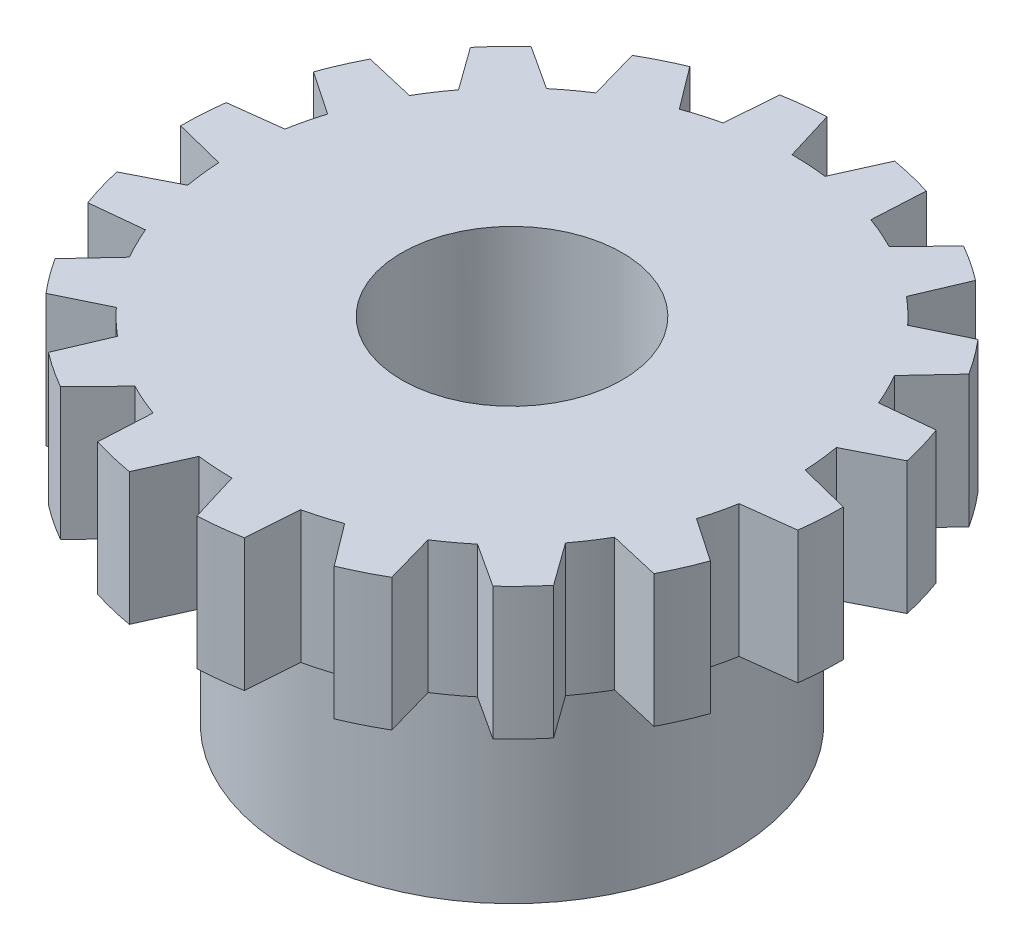
from build123d import *

# Parameters (mm, degrees)
SKETCH1_R           = 7.5
BOSS_EXTRUDE1_DEPTH = 3
SKETCH2_R           = 5
BOSS_EXTRUDE2_DEPTH = 5
CUT_EXTRUDE1_REACH  = 10
SKETCH3_R           = 2.5
CUT_EXTRUDE2_REACH  = 10


with BuildPart() as part:
    # Sketch1 → Boss-Extrude1 (new body)
    with BuildSketch(Plane(origin=(0, 0, 0), x_dir=(1, 0, 0), z_dir=(0, 1, 0))):
        Circle(SKETCH1_R)
    extrude(amount=BOSS_EXTRUDE1_DEPTH)

    # Sketch2 → Boss-Extrude2 (add)
    with BuildSketch(Plane(origin=(0, 0, 0), x_dir=(-1, 0, 0), z_dir=(0, -1, 0))):
        Circle(SKETCH2_R)
    extrude(amount=BOSS_EXTRUDE2_DEPTH)

    # Sketch3 → Cut-Extrude1 (cut, up to next)
    with BuildSketch(Plane(origin=(0, 3, 0), x_dir=(1, 0, 0), z_dir=(0, 1, 0)), mode=Mode.PRIVATE) as cut_extrude1_sk1:
        Circle(SKETCH3_R)
    cut_extrude1_tool1 = extrude(cut_extrude1_sk1.sketch, amount=-CUT_EXTRUDE1_REACH, mode=Mode.PRIVATE) & part.part
    add(cut_extrude1_tool1.solids().sort_by_distance((0, 3, 0))[0], mode=Mode.SUBTRACT)

    # Sketch4 → Cut-Extrude2 (cut, up to next)
    with BuildSketch(Plane(origin=(0, 3, 0), x_dir=(1, 0, 0), z_dir=(0, 1, 0)), mode=Mode.PRIVATE) as cut_extrude2_sk1:
        with BuildLine():
            Line((-1.289148398, -7.388375762), (-0.799951005, -6.299410956))
            ThreePointArc((-0.799951005, -6.299410956), (-0.400774519, -6.337340119), (0, -6.35))
            Line((0, -6.35), (0.348116052, -7.491916658))
            ThreePointArc((0.348116052, -7.491916658), (-0.473355731, -7.485047385), (-1.289148398, -7.388375762))
        make_face()
    cut_extrude2_tool1 = extrude(cut_extrude2_sk1.sketch, amount=-CUT_EXTRUDE2_REACH, mode=Mode.PRIVATE) & part.part
    add(cut_extrude2_tool1.solids().sort_by_distance((-0.440605, 3, 6.967167))[0], mode=Mode.SUBTRACT)
    # Sketch4 → Cut-Extrude2 (cut, up to next)
    with BuildSketch(Plane(origin=(0, 3, 0), x_dir=(1, 0, 0), z_dir=(0, 1, 0)), mode=Mode.PRIVATE) as cut_extrude2_sk2:
        with BuildLine():
            Line((-2.235264324, -7.159161501), (-2.17182791, -5.967048142))
            ThreePointArc((-2.17182791, -5.967048142), (-2.544102834, -5.818078787), (-2.906233494, -5.645910633))
            Line((-2.906233494, -5.645910633), (-3.738376574, -6.501887464))
            ThreePointArc((-3.738376574, -6.501887464), (-3.004845867, -6.871746599), (-2.235264324, -7.159161501))
        make_face()
    cut_extrude2_tool2 = extrude(cut_extrude2_sk2.sketch, amount=-CUT_EXTRUDE2_REACH, mode=Mode.PRIVATE) & part.part
    add(cut_extrude2_tool2.solids().sort_by_distance((-2.796945, 3, 6.3963))[0], mode=Mode.SUBTRACT)
    # Sketch4 → Cut-Extrude2 (cut, up to next)
    with BuildSketch(Plane(origin=(0, 3, 0), x_dir=(1, 0, 0), z_dir=(0, 1, 0)), mode=Mode.PRIVATE) as cut_extrude2_sk3:
        with BuildLine():
            Line((-4.549038834, -5.962905809), (-4.081701322, -4.864382214))
            ThreePointArc((-4.081701322, -4.864382214), (-4.3805748, -4.597071287), (-4.661981333, -4.311430164))
            Line((-4.661981333, -4.311430164), (-5.736701363, -4.831175579))
            ThreePointArc((-5.736701363, -4.831175579), (-5.173907244, -5.429611756), (-4.549038834, -5.962905809))
        make_face()
    cut_extrude2_tool3 = extrude(cut_extrude2_sk3.sketch, amount=-CUT_EXTRUDE2_REACH, mode=Mode.PRIVATE) & part.part
    add(cut_extrude2_tool3.solids().sort_by_distance((-4.815932, 3, 5.053944))[0], mode=Mode.SUBTRACT)
    # Sketch4 → Cut-Extrude2 (cut, up to next)
    with BuildSketch(Plane(origin=(0, 3, 0), x_dir=(1, 0, 0), z_dir=(0, 1, 0)), mode=Mode.PRIVATE) as cut_extrude2_sk4:
        with BuildLine():
            Line((-6.314132123, -4.047435674), (-5.499261314, -3.175))
            ThreePointArc((-5.499261314, -3.175), (-5.688684795, -2.821589145), (-5.855425419, -2.456927586))
            Line((-5.855425419, -2.456927586), (-7.043095302, -2.577752619))
            ThreePointArc((-7.043095302, -2.577752619), (-6.718919049, -3.332585604), (-6.314132123, -4.047435674))
        make_face()
    cut_extrude2_tool4 = extrude(cut_extrude2_sk4.sketch, amount=-CUT_EXTRUDE2_REACH, mode=Mode.PRIVATE) & part.part
    add(cut_extrude2_tool4.solids().sort_by_distance((-6.254046, 3, 3.102009))[0], mode=Mode.SUBTRACT)
    # Sketch4 → Cut-Extrude2 (cut, up to next)
    with BuildSketch(Plane(origin=(0, 3, 0), x_dir=(1, 0, 0), z_dir=(0, 1, 0)), mode=Mode.PRIVATE) as cut_extrude2_sk5:
        with BuildLine():
            Line((-7.317647892, -1.643785062), (-6.253529232, -1.102665928))
            ThreePointArc((-6.253529232, -1.102665928), (-6.310655448, -0.705781709), (-6.342618783, -0.306083282))
            Line((-6.342618783, -0.306083282), (-7.499988003, -0.01341465))
            ThreePointArc((-7.499988003, -0.01341465), (-7.453530056, -0.833600444), (-7.317647892, -1.643785062))
        make_face()
    cut_extrude2_tool5 = extrude(cut_extrude2_sk5.sketch, amount=-CUT_EXTRUDE2_REACH, mode=Mode.PRIVATE) & part.part
    add(cut_extrude2_tool5.solids().sort_by_distance((-6.93783, 3, 0.775925))[0], mode=Mode.SUBTRACT)
    # Sketch4 → Cut-Extrude2 (cut, up to next)
    with BuildSketch(Plane(origin=(0, 3, 0), x_dir=(1, 0, 0), z_dir=(0, 1, 0)), mode=Mode.PRIVATE) as cut_extrude2_sk6:
        with BuildLine():
            Line((-7.438547328, 0.958130288), (-6.253529232, 1.102665928))
            ThreePointArc((-6.253529232, 1.102665928), (-6.171467918, 1.495153417), (-6.064798715, 1.881679184))
            Line((-6.064798715, 1.881679184), (-7.052271463, 2.552541324))
            ThreePointArc((-7.052271463, 2.552541324), (-7.289135336, 1.765929232), (-7.438547328, 0.958130288))
        make_face()
    cut_extrude2_tool6 = extrude(cut_extrude2_sk6.sketch, amount=-CUT_EXTRUDE2_REACH, mode=Mode.PRIVATE) & part.part
    add(cut_extrude2_tool6.solids().sort_by_distance((-6.78481, 3, -1.643747))[0], mode=Mode.SUBTRACT)
    # Sketch4 → Cut-Extrude2 (cut, up to next)
    with BuildSketch(Plane(origin=(0, 3, 0), x_dir=(1, 0, 0), z_dir=(0, 1, 0)), mode=Mode.PRIVATE) as cut_extrude2_sk7:
        with BuildLine():
            Line((-6.662248175, 3.444480985), (-5.499261314, 3.175))
            ThreePointArc((-5.499261314, 3.175), (-5.287910276, 3.515750974), (-5.055474414, 3.84248337))
            Line((-5.055474414, 3.84248337), (-5.753946904, 4.810623143))
            ThreePointArc((-5.753946904, 4.810623143), (-6.245563318, 4.152461781), (-6.662248175, 3.444480985))
        make_face()
    cut_extrude2_tool7 = extrude(cut_extrude2_sk7.sketch, amount=-CUT_EXTRUDE2_REACH, mode=Mode.PRIVATE) & part.part
    add(cut_extrude2_tool7.solids().sort_by_distance((-5.813441, 3, -3.865159))[0], mode=Mode.SUBTRACT)
    # Sketch4 → Cut-Extrude2 (cut, up to next)
    with BuildSketch(Plane(origin=(0, 3, 0), x_dir=(1, 0, 0), z_dir=(0, 1, 0)), mode=Mode.PRIVATE) as cut_extrude2_sk8:
        with BuildLine():
            Line((-5.082383568, 5.51537644), (-4.081701322, 4.864382214))
            ThreePointArc((-4.081701322, 4.864382214), (-3.766552614, 5.112297078), (-3.436385289, 5.339827352))
            Line((-3.436385289, 5.339827352), (-3.761611429, 6.488472814))
            ThreePointArc((-3.761611429, 6.488472814), (-4.448684189, 6.038146155), (-5.082383568, 5.51537644))
        make_face()
    cut_extrude2_tool8 = extrude(cut_extrude2_sk8.sketch, amount=-CUT_EXTRUDE2_REACH, mode=Mode.PRIVATE) & part.part
    add(cut_extrude2_tool8.solids().sort_by_distance((-4.140886, 3, -5.620375))[0], mode=Mode.SUBTRACT)
    # Sketch4 → Cut-Extrude2 (cut, up to next)
    with BuildSketch(Plane(origin=(0, 3, 0), x_dir=(1, 0, 0), z_dir=(0, 1, 0)), mode=Mode.PRIVATE) as cut_extrude2_sk9:
        with BuildLine():
            Line((-2.889508494, 6.921036097), (-2.17182791, 5.967048142))
            ThreePointArc((-2.17182791, 5.967048142), (-1.790893118, 6.092224704), (-1.402817382, 6.193109348))
            Line((-1.402817382, 6.193109348), (-1.3155701, 7.383716903))
            ThreePointArc((-1.3155701, 7.383716903), (-2.115228092, 7.195540989), (-2.889508494, 6.921036097))
        make_face()
    cut_extrude2_tool9 = extrude(cut_extrude2_sk9.sketch, amount=-CUT_EXTRUDE2_REACH, mode=Mode.PRIVATE) & part.part
    add(cut_extrude2_tool9.solids().sort_by_distance((-1.968878, 3, -6.697691))[0], mode=Mode.SUBTRACT)
    # Sketch4 → Cut-Extrude2 (cut, up to next)
    with BuildSketch(Plane(origin=(0, 3, 0), x_dir=(1, 0, 0), z_dir=(0, 1, 0)), mode=Mode.PRIVATE) as cut_extrude2_sk10:
        with BuildLine():
            Line((-0.348116052, 7.491916658), (0, 6.35))
            ThreePointArc((0, 6.35), (0.400774519, 6.337340119), (0.799951005, 6.299410956))
            Line((0.799951005, 6.299410956), (1.289148398, 7.388375762))
            ThreePointArc((1.289148398, 7.388375762), (0.473355731, 7.485047385), (-0.348116052, 7.491916658))
        make_face()
    cut_extrude2_tool10 = extrude(cut_extrude2_sk10.sketch, amount=-CUT_EXTRUDE2_REACH, mode=Mode.PRIVATE) & part.part
    add(cut_extrude2_tool10.solids().sort_by_distance((0.440605, 3, -6.967167))[0], mode=Mode.SUBTRACT)
    # Sketch4 → Cut-Extrude2 (cut, up to next)
    with BuildSketch(Plane(origin=(0, 3, 0), x_dir=(1, 0, 0), z_dir=(0, 1, 0)), mode=Mode.PRIVATE) as cut_extrude2_sk11:
        with BuildLine():
            Line((2.235264324, 7.159161501), (2.17182791, 5.967048142))
            ThreePointArc((2.17182791, 5.967048142), (2.544102834, 5.818078787), (2.906233494, 5.645910633))
            Line((2.906233494, 5.645910633), (3.738376574, 6.501887464))
            ThreePointArc((3.738376574, 6.501887464), (3.004845867, 6.871746599), (2.235264324, 7.159161501))
        make_face()
    cut_extrude2_tool11 = extrude(cut_extrude2_sk11.sketch, amount=-CUT_EXTRUDE2_REACH, mode=Mode.PRIVATE) & part.part
    add(cut_extrude2_tool11.solids().sort_by_distance((2.796945, 3, -6.3963))[0], mode=Mode.SUBTRACT)
    # Sketch4 → Cut-Extrude2 (cut, up to next)
    with BuildSketch(Plane(origin=(0, 3, 0), x_dir=(1, 0, 0), z_dir=(0, 1, 0)), mode=Mode.PRIVATE) as cut_extrude2_sk12:
        with BuildLine():
            Line((4.549038834, 5.962905809), (4.081701322, 4.864382214))
            ThreePointArc((4.081701322, 4.864382214), (4.3805748, 4.597071287), (4.661981333, 4.311430164))
            Line((4.661981333, 4.311430164), (5.736701363, 4.831175579))
            ThreePointArc((5.736701363, 4.831175579), (5.173907244, 5.429611756), (4.549038834, 5.962905809))
        make_face()
    cut_extrude2_tool12 = extrude(cut_extrude2_sk12.sketch, amount=-CUT_EXTRUDE2_REACH, mode=Mode.PRIVATE) & part.part
    add(cut_extrude2_tool12.solids().sort_by_distance((4.815932, 3, -5.053944))[0], mode=Mode.SUBTRACT)
    # Sketch4 → Cut-Extrude2 (cut, up to next)
    with BuildSketch(Plane(origin=(0, 3, 0), x_dir=(1, 0, 0), z_dir=(0, 1, 0)), mode=Mode.PRIVATE) as cut_extrude2_sk13:
        with BuildLine():
            Line((6.314132123, 4.047435674), (5.499261314, 3.175))
            ThreePointArc((5.499261314, 3.175), (5.688684795, 2.821589145), (5.855425419, 2.456927586))
            Line((5.855425419, 2.456927586), (7.043095302, 2.577752619))
            ThreePointArc((7.043095302, 2.577752619), (6.718919049, 3.332585604), (6.314132123, 4.047435674))
        make_face()
    cut_extrude2_tool13 = extrude(cut_extrude2_sk13.sketch, amount=-CUT_EXTRUDE2_REACH, mode=Mode.PRIVATE) & part.part
    add(cut_extrude2_tool13.solids().sort_by_distance((6.254046, 3, -3.102009))[0], mode=Mode.SUBTRACT)
    # Sketch4 → Cut-Extrude2 (cut, up to next)
    with BuildSketch(Plane(origin=(0, 3, 0), x_dir=(1, 0, 0), z_dir=(0, 1, 0)), mode=Mode.PRIVATE) as cut_extrude2_sk14:
        with BuildLine():
            Line((7.317647892, 1.643785062), (6.253529232, 1.102665928))
            ThreePointArc((6.253529232, 1.102665928), (6.310655448, 0.705781709), (6.342618783, 0.306083282))
            Line((6.342618783, 0.306083282), (7.499988003, 0.01341465))
            ThreePointArc((7.499988003, 0.01341465), (7.453530056, 0.833600444), (7.317647892, 1.643785062))
        make_face()
    cut_extrude2_tool14 = extrude(cut_extrude2_sk14.sketch, amount=-CUT_EXTRUDE2_REACH, mode=Mode.PRIVATE) & part.part
    add(cut_extrude2_tool14.solids().sort_by_distance((6.93783, 3, -0.775925))[0], mode=Mode.SUBTRACT)
    # Sketch4 → Cut-Extrude2 (cut, up to next)
    with BuildSketch(Plane(origin=(0, 3, 0), x_dir=(1, 0, 0), z_dir=(0, 1, 0)), mode=Mode.PRIVATE) as cut_extrude2_sk15:
        with BuildLine():
            Line((7.438547328, -0.958130288), (6.253529232, -1.102665928))
            ThreePointArc((6.253529232, -1.102665928), (6.171467918, -1.495153417), (6.064798715, -1.881679184))
            Line((6.064798715, -1.881679184), (7.052271463, -2.552541324))
            ThreePointArc((7.052271463, -2.552541324), (7.289135336, -1.765929232), (7.438547328, -0.958130288))
        make_face()
    cut_extrude2_tool15 = extrude(cut_extrude2_sk15.sketch, amount=-CUT_EXTRUDE2_REACH, mode=Mode.PRIVATE) & part.part
    add(cut_extrude2_tool15.solids().sort_by_distance((6.78481, 3, 1.643747))[0], mode=Mode.SUBTRACT)
    # Sketch4 → Cut-Extrude2 (cut, up to next)
    with BuildSketch(Plane(origin=(0, 3, 0), x_dir=(1, 0, 0), z_dir=(0, 1, 0)), mode=Mode.PRIVATE) as cut_extrude2_sk16:
        with BuildLine():
            Line((6.662248175, -3.444480985), (5.499261314, -3.175))
            ThreePointArc((5.499261314, -3.175), (5.287910276, -3.515750974), (5.055474414, -3.84248337))
            Line((5.055474414, -3.84248337), (5.753946904, -4.810623143))
            ThreePointArc((5.753946904, -4.810623143), (6.245563318, -4.152461781), (6.662248175, -3.444480985))
        make_face()
    cut_extrude2_tool16 = extrude(cut_extrude2_sk16.sketch, amount=-CUT_EXTRUDE2_REACH, mode=Mode.PRIVATE) & part.part
    add(cut_extrude2_tool16.solids().sort_by_distance((5.813441, 3, 3.865159))[0], mode=Mode.SUBTRACT)
    # Sketch4 → Cut-Extrude2 (cut, up to next)
    with BuildSketch(Plane(origin=(0, 3, 0), x_dir=(1, 0, 0), z_dir=(0, 1, 0)), mode=Mode.PRIVATE) as cut_extrude2_sk17:
        with BuildLine():
            Line((5.082383568, -5.51537644), (4.081701322, -4.864382214))
            ThreePointArc((4.081701322, -4.864382214), (3.766552614, -5.112297078), (3.436385289, -5.339827352))
            Line((3.436385289, -5.339827352), (3.761611429, -6.488472814))
            ThreePointArc((3.761611429, -6.488472814), (4.448684189, -6.038146155), (5.082383568, -5.51537644))
        make_face()
    cut_extrude2_tool17 = extrude(cut_extrude2_sk17.sketch, amount=-CUT_EXTRUDE2_REACH, mode=Mode.PRIVATE) & part.part
    add(cut_extrude2_tool17.solids().sort_by_distance((4.140886, 3, 5.620375))[0], mode=Mode.SUBTRACT)
    # Sketch4 → Cut-Extrude2 (cut, up to next)
    with BuildSketch(Plane(origin=(0, 3, 0), x_dir=(1, 0, 0), z_dir=(0, 1, 0)), mode=Mode.PRIVATE) as cut_extrude2_sk18:
        with BuildLine():
            Line((2.889508494, -6.921036097), (2.17182791, -5.967048142))
            ThreePointArc((2.17182791, -5.967048142), (1.790893118, -6.092224704), (1.402817382, -6.193109348))
            Line((1.402817382, -6.193109348), (1.3155701, -7.383716903))
            ThreePointArc((1.3155701, -7.383716903), (2.115228092, -7.195540989), (2.889508494, -6.921036097))
        make_face()
    cut_extrude2_tool18 = extrude(cut_extrude2_sk18.sketch, amount=-CUT_EXTRUDE2_REACH, mode=Mode.PRIVATE) & part.part
    add(cut_extrude2_tool18.solids().sort_by_distance((1.968878, 3, 6.697691))[0], mode=Mode.SUBTRACT)


solid = part.part
